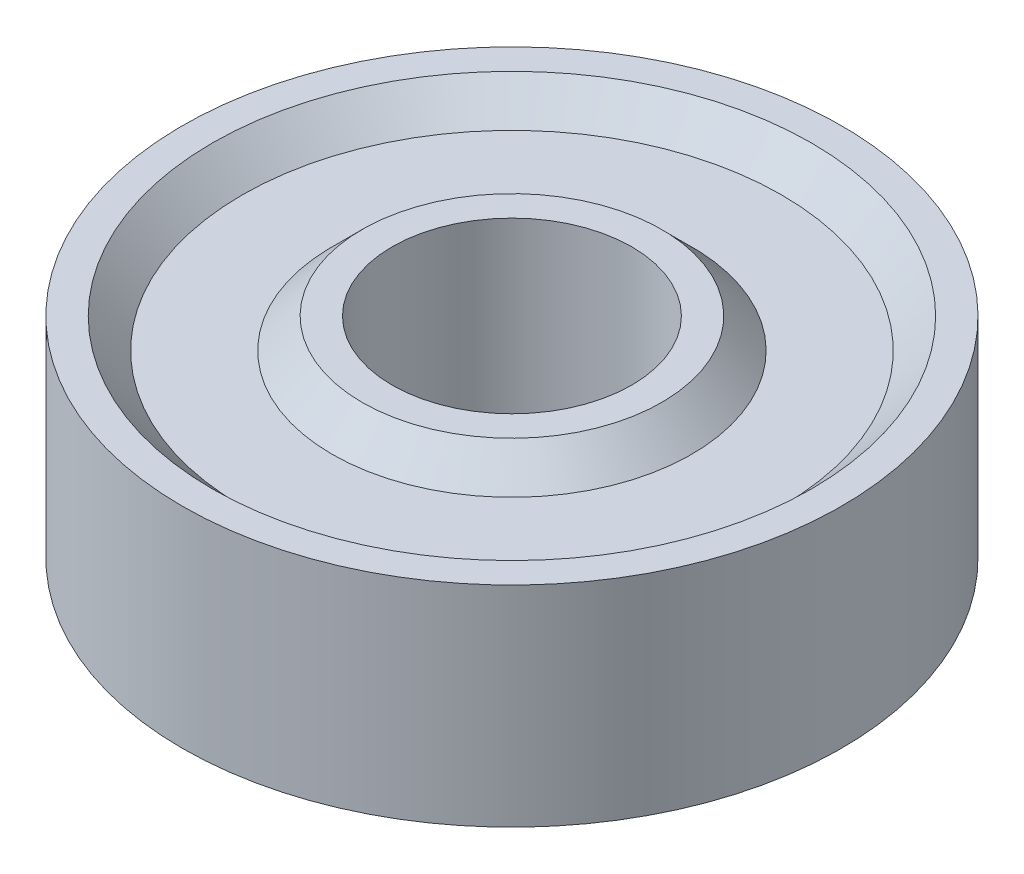
from build123d import *


with BuildPart() as part:
    # Sketch1 → Revolve1 (revolve)
    with BuildSketch(Plane.XY):
        Polygon((4, 3.5), (4, -3.5), (5, -3.5), (6, -2.5), (9, -2.5), (10, -3.5), (11, -3.5), (11, 3.5), (10, 3.5), (9, 2.5), (6, 2.5), (5, 3.5), align=None)
    revolve(axis=Axis((0, 0, 0), (0, -1, 0)))


solid = part.part
